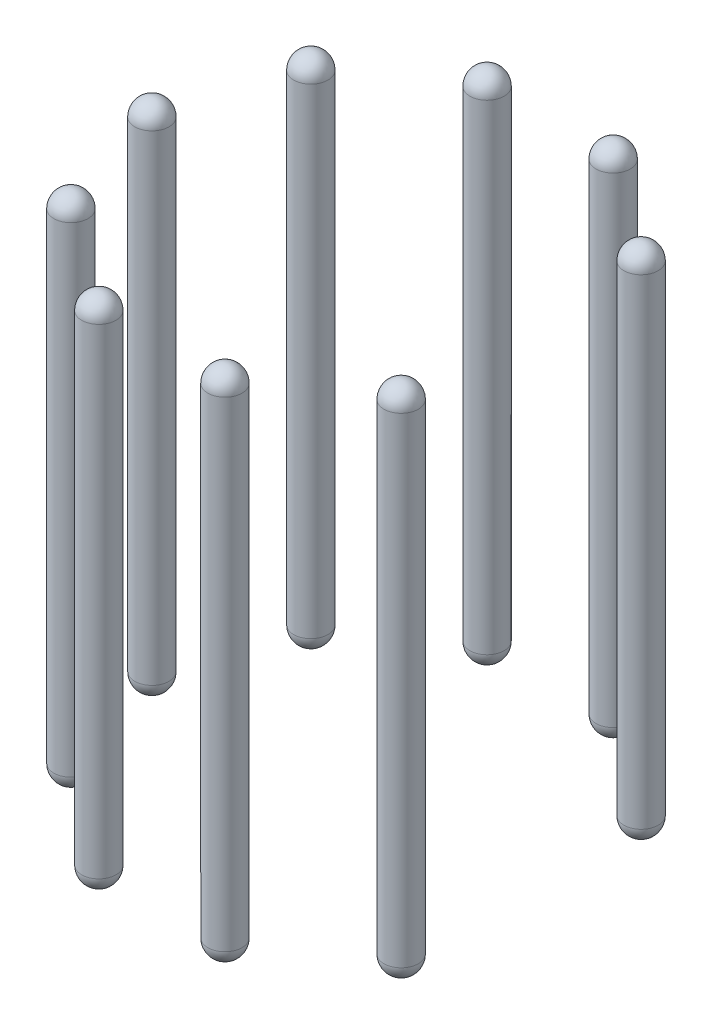
from build123d import *


with BuildPart() as part:
    # Sketch1 → Revolve1 (revolve)
    with BuildSketch(Plane(origin=(0, 0, 0), x_dir=(0.809016994, 0, -0.587785252), z_dir=(0.587785252, 0, 0.809016994))):
        with BuildLine():
            Line((6.45, 8), (6.45, -6))
            ThreePointArc((6.45, -6), (6.303553391, -6.353553391), (5.95, -6.5))
            Line((5.95, -6.5), (5.95, 8.5))
            ThreePointArc((5.95, 8.5), (6.303553391, 8.353553391), (6.45, 8))
        make_face()
    revolve(axis=Axis((4.813651117, -7.25, -3.497322251), (0, 1, 0)))


with BuildPart() as body_2:
    # Sketch2 → Revolve2 (revolve)
    with BuildSketch(Plane(origin=(0, 0, 0), x_dir=(0.309016994, 0, -0.951056516), z_dir=(0.951056516, 0, 0.309016994))):
        with BuildLine():
            Line((6.45, 8), (6.45, -6))
            ThreePointArc((6.45, -6), (6.303553391, -6.353553391), (5.95, -6.5))
            Line((5.95, -6.5), (5.95, 8.5))
            ThreePointArc((5.95, 8.5), (6.303553391, 8.353553391), (6.45, 8))
        make_face()
    revolve(axis=Axis((1.838651117, -7.25, -5.658786272), (0, 1, 0)))


with BuildPart() as body_3:
    # Sketch3 → Revolve3 (revolve)
    with BuildSketch(Plane(origin=(0, 0, 0), x_dir=(-0.309016994, 0, -0.951056516), z_dir=(0.951056516, 0, -0.309016994))):
        with BuildLine():
            Line((6.45, 8), (6.45, -6))
            ThreePointArc((6.45, -6), (6.303553391, -6.353553391), (5.95, -6.5))
            Line((5.95, -6.5), (5.95, 8.5))
            ThreePointArc((5.95, 8.5), (6.303553391, 8.353553391), (6.45, 8))
        make_face()
    revolve(axis=Axis((-1.838651117, -7.25, -5.658786272), (0, 1, 0)))


with BuildPart() as body_4:
    # Sketch4 → Revolve4 (revolve)
    with BuildSketch(Plane(origin=(0, 0, 0), x_dir=(-0.809016994, 0, -0.587785252), z_dir=(0.587785252, 0, -0.809016994))):
        with BuildLine():
            Line((6.45, 8), (6.45, -6))
            ThreePointArc((6.45, -6), (6.303553391, -6.353553391), (5.95, -6.5))
            Line((5.95, -6.5), (5.95, 8.5))
            ThreePointArc((5.95, 8.5), (6.303553391, 8.353553391), (6.45, 8))
        make_face()
    revolve(axis=Axis((-4.813651117, -7.25, -3.497322251), (0, 1, 0)))


with BuildPart() as body_5:
    # Sketch5 → Revolve5 (revolve)
    with BuildSketch(Plane(origin=(0, 0, 0), x_dir=(-1, 0, 0), z_dir=(0, 0, -1))):
        with BuildLine():
            Line((6.45, 8), (6.45, -6))
            ThreePointArc((6.45, -6), (6.303553391, -6.353553391), (5.95, -6.5))
            Line((5.95, -6.5), (5.95, 8.5))
            ThreePointArc((5.95, 8.5), (6.303553391, 8.353553391), (6.45, 8))
        make_face()
    revolve(axis=Axis((-5.95, -7.25, 0), (0, 1, 0)))


with BuildPart() as body_6:
    # Sketch6 → Revolve6 (revolve)
    with BuildSketch(Plane(origin=(0, 0, 0), x_dir=(-0.809016994, 0, 0.587785252), z_dir=(-0.587785252, 0, -0.809016994))):
        with BuildLine():
            Line((6.45, 8), (6.45, -6))
            ThreePointArc((6.45, -6), (6.303553391, -6.353553391), (5.95, -6.5))
            Line((5.95, -6.5), (5.95, 8.5))
            ThreePointArc((5.95, 8.5), (6.303553391, 8.353553391), (6.45, 8))
        make_face()
    revolve(axis=Axis((-4.813651117, -7.25, 3.497322251), (0, 1, 0)))


with BuildPart() as body_7:
    # Sketch7 → Revolve7 (revolve)
    with BuildSketch(Plane(origin=(0, 0, 0), x_dir=(-0.309016994, 0, 0.951056516), z_dir=(-0.951056516, 0, -0.309016994))):
        with BuildLine():
            Line((6.45, 8), (6.45, -6))
            ThreePointArc((6.45, -6), (6.303553391, -6.353553391), (5.95, -6.5))
            Line((5.95, -6.5), (5.95, 8.5))
            ThreePointArc((5.95, 8.5), (6.303553391, 8.353553391), (6.45, 8))
        make_face()
    revolve(axis=Axis((-1.838651117, -7.25, 5.658786272), (0, 1, 0)))


with BuildPart() as body_8:
    # Sketch8 → Revolve8 (revolve)
    with BuildSketch(Plane(origin=(0, 0, 0), x_dir=(0.309016994, 0, 0.951056516), z_dir=(-0.951056516, 0, 0.309016994))):
        with BuildLine():
            Line((6.45, 8), (6.45, -6))
            ThreePointArc((6.45, -6), (6.303553391, -6.353553391), (5.95, -6.5))
            Line((5.95, -6.5), (5.95, 8.5))
            ThreePointArc((5.95, 8.5), (6.303553391, 8.353553391), (6.45, 8))
        make_face()
    revolve(axis=Axis((1.838651117, -7.25, 5.658786272), (0, 1, 0)))


with BuildPart() as body_9:
    # Sketch9 → Revolve9 (revolve)
    with BuildSketch(Plane(origin=(0, 0, 0), x_dir=(0.809016994, 0, 0.587785252), z_dir=(-0.587785252, 0, 0.809016994))):
        with BuildLine():
            Line((6.45, 8), (6.45, -6))
            ThreePointArc((6.45, -6), (6.303553391, -6.353553391), (5.95, -6.5))
            Line((5.95, -6.5), (5.95, 8.5))
            ThreePointArc((5.95, 8.5), (6.303553391, 8.353553391), (6.45, 8))
        make_face()
    revolve(axis=Axis((4.813651117, -7.25, 3.497322251), (0, 1, 0)))


solid = Compound([part.part, body_2.part, body_3.part, body_4.part, body_5.part, body_6.part, body_7.part, body_8.part, body_9.part])
